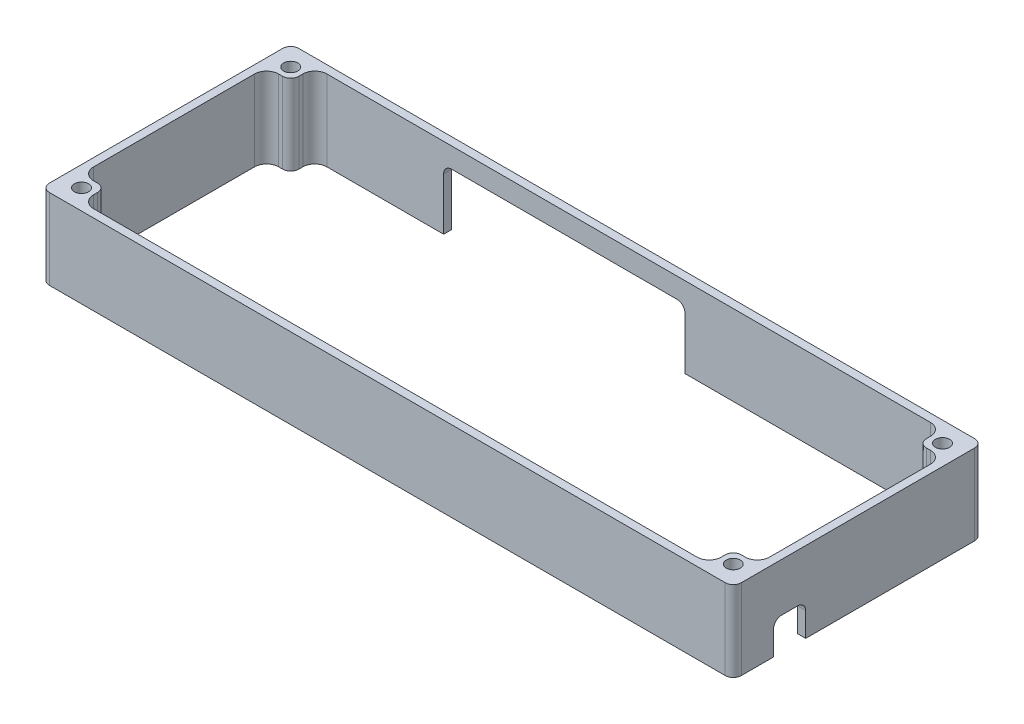
from build123d import *

# Parameters (mm, degrees)
SKETCH1_R           = 1.75
BOSS_EXTRUDE1_DEPTH = 20
CUT_EXTRUDE1_DEPTH  = 20
FILLET1_R           = 3
CUT_EXTRUDE5_DEPTH  = 10


with BuildPart() as part:
    # Sketch1 → Boss-Extrude1 (new body)
    with BuildSketch(Plane(origin=(0, 0, 0), x_dir=(1, 0, 0), z_dir=(0, 1, 0))):
        with BuildLine():
            Line((-86, 29), (-86, -29))
            ThreePointArc((-86, -29), (-85.414213562, -30.414213562), (-84, -31))
            Line((-84, -31), (84, -31))
            ThreePointArc((84, -31), (85.414213562, -30.414213562), (86, -29))
            Line((86, -29), (86, 29))
            ThreePointArc((86, 29), (85.414213562, 30.414213562), (84, 31))
            Line((84, 31), (-84, 31))
            ThreePointArc((-84, 31), (-85.414213562, 30.414213562), (-86, 29))
        make_face()
        with Locations(Location((-81, 26, 0), (0, 0, 270))):  # turned: the seam where the file's is
            Circle(SKETCH1_R, mode=Mode.SUBTRACT)
        with Locations(Location((-81, -26, 0), (0, 0, 270))):  # turned: the seam where the file's is
            Circle(SKETCH1_R, mode=Mode.SUBTRACT)
        with Locations(Location((81, -26, 0), (0, 0, 270))):  # turned: the seam where the file's is
            Circle(SKETCH1_R, mode=Mode.SUBTRACT)
        with Locations(Location((81, 26, 0), (0, 0, 270))):  # turned: the seam where the file's is
            Circle(SKETCH1_R, mode=Mode.SUBTRACT)
        with BuildLine():
            Line((84, -23), (80, -23))
            ThreePointArc((80, -23), (78.585786438, -23.585786438), (78, -25))
            Line((78, -25), (78, -29))
            Line((78, -29), (-78, -29))
            Line((-78, -29), (-78, -25))
            ThreePointArc((-78, -25), (-78.585786438, -23.585786438), (-80, -23))
            Line((-80, -23), (-84, -23))
            Line((-84, -23), (-84, 23))
            Line((-84, 23), (-80, 23))
            ThreePointArc((-80, 23), (-78.585786438, 23.585786438), (-78, 25))
            Line((-78, 25), (-78, 29))
            Line((-78, 29), (78, 29))
            Line((78, 29), (78, 25))
            ThreePointArc((78, 25), (78.585786438, 23.585786438), (80, 23))
            Line((80, 23), (84, 23))
            Line((84, 23), (84, -23))
        make_face(mode=Mode.SUBTRACT)
    extrude(amount=BOSS_EXTRUDE1_DEPTH)

    # Sketch2 → Cut-Extrude1 (cut)
    with BuildSketch(Plane(origin=(0, 0, -31), x_dir=(-1, 0, 0), z_dir=(0, 0, -1))):
        with BuildLine():
            Line((-12, 15), (44, 15))
            ThreePointArc((44, 15), (45.414213562, 14.414213562), (46, 13))
            Line((46, 13), (46, -3))
            Line((46, -3), (-14, -3))
            Line((-14, -3), (-14, 13))
            ThreePointArc((-14, 13), (-13.414213562, 14.414213562), (-12, 15))
        make_face()
    extrude(amount=-CUT_EXTRUDE1_DEPTH, mode=Mode.SUBTRACT)

    # Fillet1
    fillet1_edges = [part.edges().sort_by_distance(p)[0] for p in [
        (84, 10, 23),
        (84, 10, -23),
        (78, 10, -29),
        (-78, 10, -29),
        (-84, 10, -23),
        (-84, 10, 23),
        (-78, 10, 29),
        (78, 10, 29),
    ]]
    fillet(fillet1_edges, radius=FILLET1_R)

    # Sketch3 → Cut-Extrude5 (cut)
    with BuildSketch(Plane(origin=(86, 0, 0), x_dir=(0, 0, -1), z_dir=(1, 0, 0))):
        with BuildLine():
            Line((-13, 0), (-13, 6))
            ThreePointArc((-13, 6), (-13.585786438, 7.414213562), (-15, 8))
            Line((-15, 8), (-19, 8))
            ThreePointArc((-19, 8), (-20.414213562, 7.414213562), (-21, 6))
            Line((-21, 6), (-21, 0))
            Line((-21, 0), (-13, 0))
        make_face()
    extrude(amount=-CUT_EXTRUDE5_DEPTH, mode=Mode.SUBTRACT)


solid = part.part
